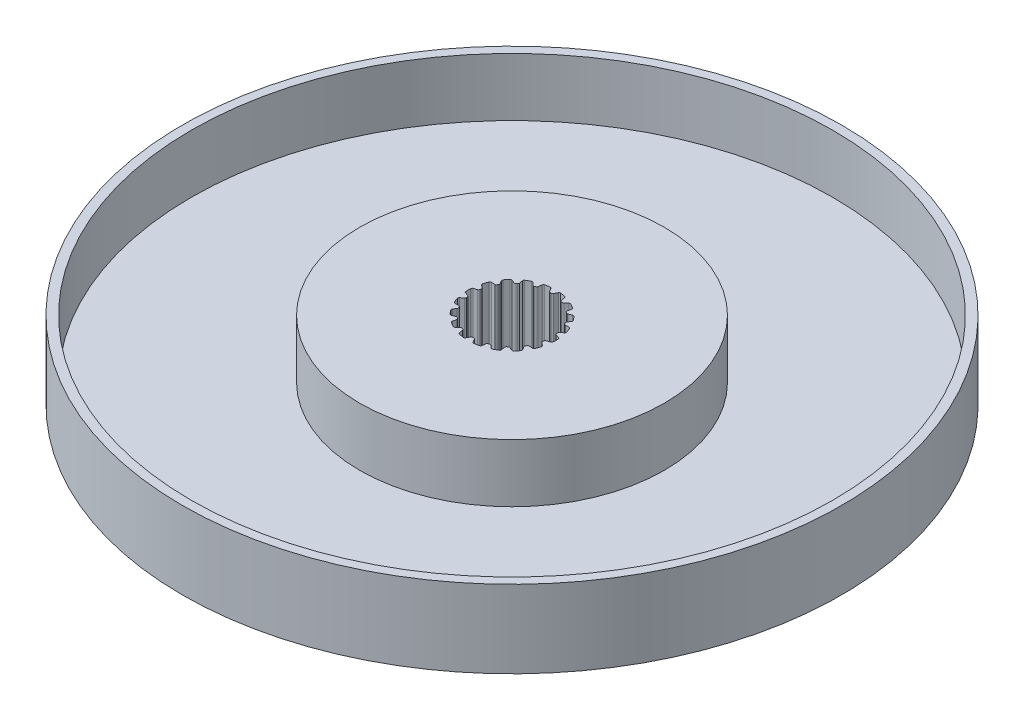
from build123d import *

# Parameters (mm, degrees)
SKETCH1_R           = 42.5
BOSS_EXTRUDE1_DEPTH = 10
SKETCH3_R           = 41.35
SKETCH3_R_2         = 19.65
CUT_EXTRUDE2_DEPTH  = 7.5
CUT_EXTRUDE4_DEPTH  = 11


with BuildPart() as part:
    # Sketch1 → Boss-Extrude1 (new body)
    with BuildSketch(Plane(origin=(0, 0, 0), x_dir=(1, 0, 0), z_dir=(0, 1, 0))):
        Circle(SKETCH1_R)
    extrude(amount=BOSS_EXTRUDE1_DEPTH)

    # Sketch3 → Cut-Extrude2 (cut)
    with BuildSketch(Plane(origin=(0, 10, 0), x_dir=(1, 0, 0), z_dir=(0, 1, 0))):
        Circle(SKETCH3_R)
        Circle(SKETCH3_R_2, mode=Mode.SUBTRACT)
    extrude(amount=-CUT_EXTRUDE2_DEPTH, mode=Mode.SUBTRACT)

    # Sketch4 → Cut-Extrude4 (cut, through all)
    with BuildSketch(Plane(origin=(0, 10, 0), x_dir=(1, 0, 0), z_dir=(0, 1, 0))):
        with BuildLine():
            Line((-0.464262334, 5.50608508), (-0.251589519, 5.106105687))
            ThreePointArc((-0.251589519, 5.106105687), (-0.178007615, 5.02856654), (-0.075, 5))
            Line((-0.075, 5), (0.075, 5))
            ThreePointArc((0.075, 5), (0.178007615, 5.02856654), (0.251589519, 5.106105687))
            Line((0.251589519, 5.106105687), (0.464262334, 5.50608508))
            ThreePointArc((0.464262334, 5.50608508), (0.548119788, 5.589393375), (0.664369352, 5.610803273))
            ThreePointArc((0.664369352, 5.610803273), (0.981112204, 5.564163805), (1.294704762, 5.499658133))
            ThreePointArc((1.294704762, 5.499658133), (1.396621003, 5.439779718), (1.446928119, 5.332814589))
            Line((1.446928119, 5.332814589), (1.509974185, 4.884218519))
            ThreePointArc((1.509974185, 4.884218519), (1.552598606, 4.786189061), (1.63962377, 4.724114615))
            Line((1.63962377, 4.724114615), (1.780577663, 4.672811593))
            ThreePointArc((1.780577663, 4.672811593), (1.887143491, 4.664424681), (1.982807813, 4.712121152))
            Line((1.982807813, 4.712121152), (2.319455898, 5.015240449))
            ThreePointArc((2.319455898, 5.015240449), (2.426749244, 5.064843701), (2.543310717, 5.045202731))
            ThreePointArc((2.543310717, 5.045202731), (2.825, 4.893043531), (3.097618374, 4.725173056))
            ThreePointArc((3.097618374, 4.725173056), (3.172908689, 4.634048344), (3.183597686, 4.516327955))
            Line((3.183597686, 4.516327955), (3.089412717, 4.073222513))
            ThreePointArc((3.089412717, 4.073222513), (3.095938522, 3.966526544), (3.156484715, 3.878431286))
            Line((3.156484715, 3.878431286), (3.271391382, 3.782013145))
            ThreePointArc((3.271391382, 3.782013145), (3.368662011, 3.737684365), (3.474870222, 3.749785263))
            Line((3.474870222, 3.749785263), (3.894888848, 3.919483803))
            ThreePointArc((3.894888848, 3.919483803), (4.012676925, 3.929399127), (4.115491274, 3.871076281))
            ThreePointArc((4.115491274, 3.871076281), (4.328151104, 3.631749995), (4.526913494, 3.380762372))
            ThreePointArc((4.526913494, 3.380762372), (4.566496761, 3.269382349), (4.536278388, 3.155105515))
            Line((4.536278388, 3.155105515), (4.29622248, 2.770935758))
            ThreePointArc((4.29622248, 2.770935758), (4.265862561, 2.668442387), (4.292627019, 2.564951905))
            Line((4.292627019, 2.564951905), (4.367627019, 2.435048095))
            ThreePointArc((4.367627019, 2.435048095), (4.443870176, 2.360124153), (4.547811999, 2.335169929))
            Line((4.547811999, 2.335169929), (5.000540722, 2.350979565))
            ThreePointArc((5.000540722, 2.350979565), (5.114616549, 2.320011027), (5.191282846, 2.2300409))
            ThreePointArc((5.191282846, 2.2300409), (5.309263307, 1.93241381), (5.410196036, 1.628581852))
            ThreePointArc((5.410196036, 1.628581852), (5.409297928, 1.510380591), (5.341816967, 1.413330786))
            Line((5.341816967, 1.413330786), (4.984844407, 1.134433256))
            ThreePointArc((4.984844407, 1.134433256), (4.921260617, 1.048504695), (4.911015152, 0.94210147))
            Line((4.911015152, 0.94210147), (4.937062378, 0.794380307))
            ThreePointArc((4.937062378, 0.794380307), (4.983082013, 0.697898137), (5.07222053, 0.638898639))
            Line((5.07222053, 0.638898639), (5.503053584, 0.498912494))
            ThreePointArc((5.503053584, 0.498912494), (5.599657933, 0.430795357), (5.640929091, 0.320029675))
            ThreePointArc((5.640929091, 0.320029675), (5.65, 0), (5.640929091, -0.320029675))
            ThreePointArc((5.640929091, -0.320029675), (5.599657933, -0.430795357), (5.503053584, -0.498912494))
            Line((5.503053584, -0.498912494), (5.07222053, -0.638898639))
            ThreePointArc((5.07222053, -0.638898639), (4.983082013, -0.697898137), (4.937062378, -0.794380307))
            Line((4.937062378, -0.794380307), (4.911015152, -0.94210147))
            ThreePointArc((4.911015152, -0.94210147), (4.921260617, -1.048504695), (4.984844407, -1.134433256))
            Line((4.984844407, -1.134433256), (5.341816967, -1.413330786))
            ThreePointArc((5.341816967, -1.413330786), (5.409297928, -1.510380591), (5.410196036, -1.628581852))
            ThreePointArc((5.410196036, -1.628581852), (5.309263307, -1.93241381), (5.191282846, -2.2300409))
            ThreePointArc((5.191282846, -2.2300409), (5.114616549, -2.320011027), (5.000540722, -2.350979565))
            Line((5.000540722, -2.350979565), (4.547811999, -2.335169929))
            ThreePointArc((4.547811999, -2.335169929), (4.443870176, -2.360124153), (4.367627019, -2.435048095))
            Line((4.367627019, -2.435048095), (4.292627019, -2.564951905))
            ThreePointArc((4.292627019, -2.564951905), (4.265862561, -2.668442387), (4.29622248, -2.770935758))
            Line((4.29622248, -2.770935758), (4.536278388, -3.155105515))
            ThreePointArc((4.536278388, -3.155105515), (4.566496761, -3.269382349), (4.526913494, -3.380762372))
            ThreePointArc((4.526913494, -3.380762372), (4.328151104, -3.631749995), (4.115491274, -3.871076281))
            ThreePointArc((4.115491274, -3.871076281), (4.012676925, -3.929399127), (3.894888848, -3.919483803))
            Line((3.894888848, -3.919483803), (3.474870222, -3.749785263))
            ThreePointArc((3.474870222, -3.749785263), (3.368662011, -3.737684365), (3.271391382, -3.782013145))
            Line((3.271391382, -3.782013145), (3.156484715, -3.878431286))
            ThreePointArc((3.156484715, -3.878431286), (3.095938522, -3.966526544), (3.089412717, -4.073222513))
            Line((3.089412717, -4.073222513), (3.183597686, -4.516327955))
            ThreePointArc((3.183597686, -4.516327955), (3.172908689, -4.634048344), (3.097618374, -4.725173056))
            ThreePointArc((3.097618374, -4.725173056), (2.825, -4.893043531), (2.543310717, -5.045202731))
            ThreePointArc((2.543310717, -5.045202731), (2.426749244, -5.064843701), (2.319455898, -5.015240449))
            Line((2.319455898, -5.015240449), (1.982807813, -4.712121152))
            ThreePointArc((1.982807813, -4.712121152), (1.887143491, -4.664424681), (1.780577663, -4.672811593))
            Line((1.780577663, -4.672811593), (1.63962377, -4.724114615))
            ThreePointArc((1.63962377, -4.724114615), (1.552598606, -4.786189061), (1.509974185, -4.884218519))
            Line((1.509974185, -4.884218519), (1.446928119, -5.332814589))
            ThreePointArc((1.446928119, -5.332814589), (1.396621003, -5.439779718), (1.294704762, -5.499658133))
            ThreePointArc((1.294704762, -5.499658133), (0.981112204, -5.564163805), (0.664369352, -5.610803273))
            ThreePointArc((0.664369352, -5.610803273), (0.548119788, -5.589393375), (0.464262334, -5.50608508))
            Line((0.464262334, -5.50608508), (0.251589519, -5.106105687))
            ThreePointArc((0.251589519, -5.106105687), (0.178007615, -5.02856654), (0.075, -5))
            Line((0.075, -5), (-0.075, -5))
            ThreePointArc((-0.075, -5), (-0.178007615, -5.02856654), (-0.251589519, -5.106105687))
            Line((-0.251589519, -5.106105687), (-0.464262334, -5.50608508))
            ThreePointArc((-0.464262334, -5.50608508), (-0.548119788, -5.589393375), (-0.664369352, -5.610803273))
            ThreePointArc((-0.664369352, -5.610803273), (-0.981112204, -5.564163805), (-1.294704762, -5.499658133))
            ThreePointArc((-1.294704762, -5.499658133), (-1.396621003, -5.439779718), (-1.446928119, -5.332814589))
            Line((-1.446928119, -5.332814589), (-1.509974185, -4.884218519))
            ThreePointArc((-1.509974185, -4.884218519), (-1.552598606, -4.786189061), (-1.63962377, -4.724114615))
            Line((-1.63962377, -4.724114615), (-1.780577663, -4.672811593))
            ThreePointArc((-1.780577663, -4.672811593), (-1.887143491, -4.664424681), (-1.982807813, -4.712121152))
            Line((-1.982807813, -4.712121152), (-2.319455898, -5.015240449))
            ThreePointArc((-2.319455898, -5.015240449), (-2.426749244, -5.064843701), (-2.543310717, -5.045202731))
            ThreePointArc((-2.543310717, -5.045202731), (-2.825, -4.893043531), (-3.097618374, -4.725173056))
            ThreePointArc((-3.097618374, -4.725173056), (-3.172908689, -4.634048344), (-3.183597686, -4.516327955))
            Line((-3.183597686, -4.516327955), (-3.089412717, -4.073222513))
            ThreePointArc((-3.089412717, -4.073222513), (-3.095938522, -3.966526544), (-3.156484715, -3.878431286))
            Line((-3.156484715, -3.878431286), (-3.271391382, -3.782013145))
            ThreePointArc((-3.271391382, -3.782013145), (-3.368662011, -3.737684365), (-3.474870222, -3.749785263))
            Line((-3.474870222, -3.749785263), (-3.894888848, -3.919483803))
            ThreePointArc((-3.894888848, -3.919483803), (-4.012676925, -3.929399127), (-4.115491274, -3.871076281))
            ThreePointArc((-4.115491274, -3.871076281), (-4.328151104, -3.631749995), (-4.526913494, -3.380762372))
            ThreePointArc((-4.526913494, -3.380762372), (-4.566496761, -3.269382349), (-4.536278388, -3.155105515))
            Line((-4.536278388, -3.155105515), (-4.29622248, -2.770935758))
            ThreePointArc((-4.29622248, -2.770935758), (-4.265862561, -2.668442387), (-4.292627019, -2.564951905))
            Line((-4.292627019, -2.564951905), (-4.367627019, -2.435048095))
            ThreePointArc((-4.367627019, -2.435048095), (-4.443870176, -2.360124153), (-4.547811999, -2.335169929))
            Line((-4.547811999, -2.335169929), (-5.000540722, -2.350979565))
            ThreePointArc((-5.000540722, -2.350979565), (-5.114616549, -2.320011027), (-5.191282846, -2.2300409))
            ThreePointArc((-5.191282846, -2.2300409), (-5.309263307, -1.93241381), (-5.410196036, -1.628581852))
            ThreePointArc((-5.410196036, -1.628581852), (-5.409297928, -1.510380591), (-5.341816967, -1.413330786))
            Line((-5.341816967, -1.413330786), (-4.984844407, -1.134433256))
            ThreePointArc((-4.984844407, -1.134433256), (-4.921260617, -1.048504695), (-4.911015152, -0.94210147))
            Line((-4.911015152, -0.94210147), (-4.937062378, -0.794380307))
            ThreePointArc((-4.937062378, -0.794380307), (-4.983082013, -0.697898137), (-5.07222053, -0.638898639))
            Line((-5.07222053, -0.638898639), (-5.503053584, -0.498912494))
            ThreePointArc((-5.503053584, -0.498912494), (-5.599657933, -0.430795357), (-5.640929091, -0.320029675))
            ThreePointArc((-5.640929091, -0.320029675), (-5.65, 0), (-5.640929091, 0.320029675))
            ThreePointArc((-5.640929091, 0.320029675), (-5.599657933, 0.430795357), (-5.503053584, 0.498912494))
            Line((-5.503053584, 0.498912494), (-5.07222053, 0.638898639))
            ThreePointArc((-5.07222053, 0.638898639), (-4.983082013, 0.697898137), (-4.937062378, 0.794380307))
            Line((-4.937062378, 0.794380307), (-4.911015152, 0.94210147))
            ThreePointArc((-4.911015152, 0.94210147), (-4.921260617, 1.048504695), (-4.984844407, 1.134433256))
            Line((-4.984844407, 1.134433256), (-5.341816967, 1.413330786))
            ThreePointArc((-5.341816967, 1.413330786), (-5.409297928, 1.510380591), (-5.410196036, 1.628581852))
            ThreePointArc((-5.410196036, 1.628581852), (-5.309263307, 1.93241381), (-5.191282846, 2.2300409))
            ThreePointArc((-5.191282846, 2.2300409), (-5.114616549, 2.320011027), (-5.000540722, 2.350979565))
            Line((-5.000540722, 2.350979565), (-4.547811999, 2.335169929))
            ThreePointArc((-4.547811999, 2.335169929), (-4.443870176, 2.360124153), (-4.367627019, 2.435048095))
            Line((-4.367627019, 2.435048095), (-4.292627019, 2.564951905))
            ThreePointArc((-4.292627019, 2.564951905), (-4.265862561, 2.668442387), (-4.29622248, 2.770935758))
            Line((-4.29622248, 2.770935758), (-4.536278388, 3.155105515))
            ThreePointArc((-4.536278388, 3.155105515), (-4.566496761, 3.269382349), (-4.526913494, 3.380762372))
            ThreePointArc((-4.526913494, 3.380762372), (-4.328151104, 3.631749995), (-4.115491274, 3.871076281))
            ThreePointArc((-4.115491274, 3.871076281), (-4.012676925, 3.929399127), (-3.894888848, 3.919483803))
            Line((-3.894888848, 3.919483803), (-3.474870222, 3.749785263))
            ThreePointArc((-3.474870222, 3.749785263), (-3.368662011, 3.737684365), (-3.271391382, 3.782013145))
            Line((-3.271391382, 3.782013145), (-3.156484715, 3.878431286))
            ThreePointArc((-3.156484715, 3.878431286), (-3.095938522, 3.966526544), (-3.089412717, 4.073222513))
            Line((-3.089412717, 4.073222513), (-3.183597686, 4.516327955))
            ThreePointArc((-3.183597686, 4.516327955), (-3.172908689, 4.634048344), (-3.097618374, 4.725173056))
            ThreePointArc((-3.097618374, 4.725173056), (-2.825, 4.893043531), (-2.543310717, 5.045202731))
            ThreePointArc((-2.543310717, 5.045202731), (-2.426749244, 5.064843701), (-2.319455898, 5.015240449))
            Line((-2.319455898, 5.015240449), (-1.982807813, 4.712121152))
            ThreePointArc((-1.982807813, 4.712121152), (-1.887143491, 4.664424681), (-1.780577663, 4.672811593))
            Line((-1.780577663, 4.672811593), (-1.63962377, 4.724114615))
            ThreePointArc((-1.63962377, 4.724114615), (-1.552598606, 4.786189061), (-1.509974185, 4.884218519))
            Line((-1.509974185, 4.884218519), (-1.446928119, 5.332814589))
            ThreePointArc((-1.446928119, 5.332814589), (-1.396621003, 5.439779718), (-1.294704762, 5.499658133))
            ThreePointArc((-1.294704762, 5.499658133), (-0.981112204, 5.564163805), (-0.664369352, 5.610803273))
            ThreePointArc((-0.664369352, 5.610803273), (-0.548119788, 5.589393375), (-0.464262334, 5.50608508))
        make_face()
    extrude(amount=-CUT_EXTRUDE4_DEPTH, mode=Mode.SUBTRACT)


solid = part.part
